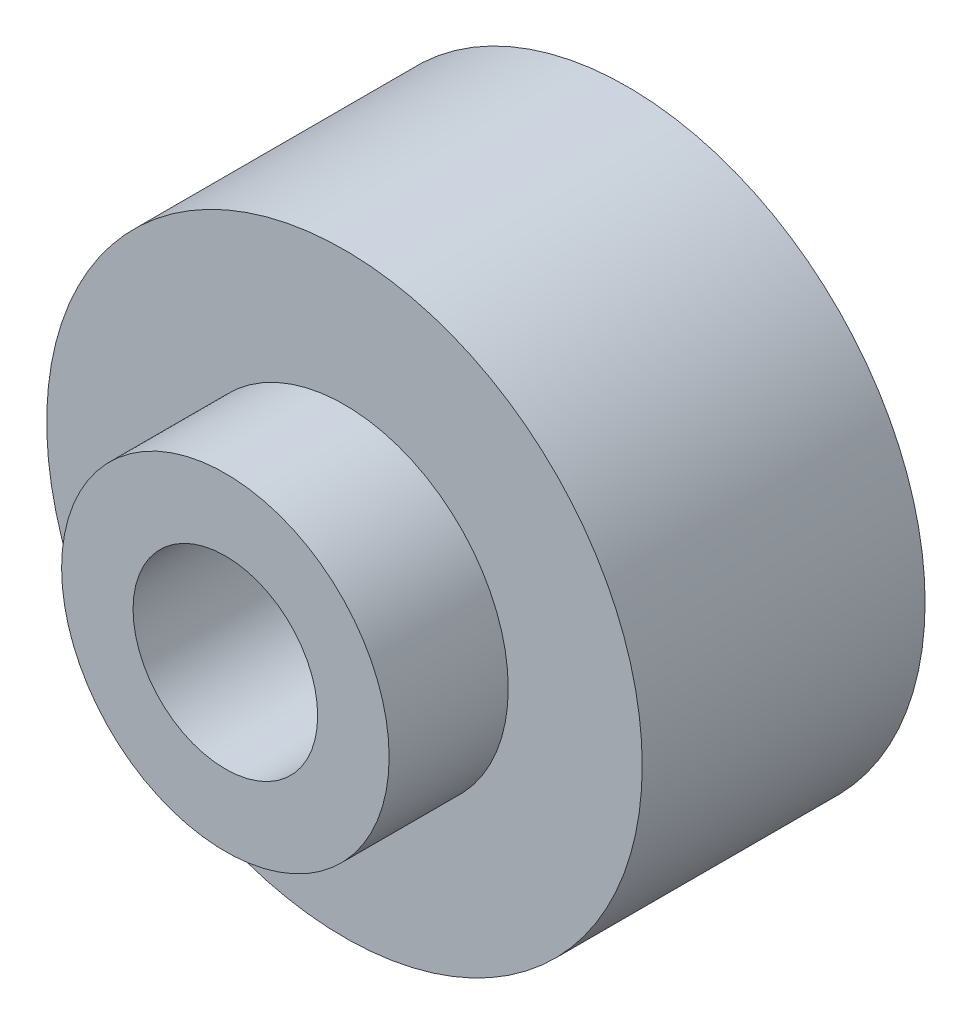
from build123d import *

# Parameters (mm, degrees)
SKETCH_1_R          = 5
SKETCH_1_R_2        = 1.55
EXTRUDE_1_DEPTH     = 4.75
SKETCH_2_R          = 2.75
SKETCH_2_R_2        = 1.55
EXTRUDE_2_DEPTH     = 2
CUT_EXTRUDE_1_DEPTH = 2.75


with BuildPart() as part:
    # 草图1 → 凸台-拉伸1 (new body)
    with BuildSketch(Plane.XY):
        Circle(SKETCH_1_R)
        Circle(SKETCH_1_R_2, mode=Mode.SUBTRACT)
    extrude(amount=EXTRUDE_1_DEPTH)

    # 草图2 → 凸台-拉伸2 (add)
    with BuildSketch(Plane.XY.offset(4.75)):
        Circle(SKETCH_2_R)
        Circle(SKETCH_2_R_2, mode=Mode.SUBTRACT)
    extrude(amount=EXTRUDE_2_DEPTH)

    # 草图3 → 切除-拉伸1 (cut)
    with BuildSketch(Plane(origin=(0, 0, 0), x_dir=(-1, 0, 0), z_dir=(0, 0, -1))):
        Polygon((1.770357817, 2.977554903), (-1.693459279, 3.021952295), (-3.463817096, 0.044397392), (-1.770357817, -2.977554903), (1.693459279, -3.021952295), (3.463817096, -0.044397392), align=None)
    extrude(amount=-CUT_EXTRUDE_1_DEPTH, mode=Mode.SUBTRACT)


solid = part.part
